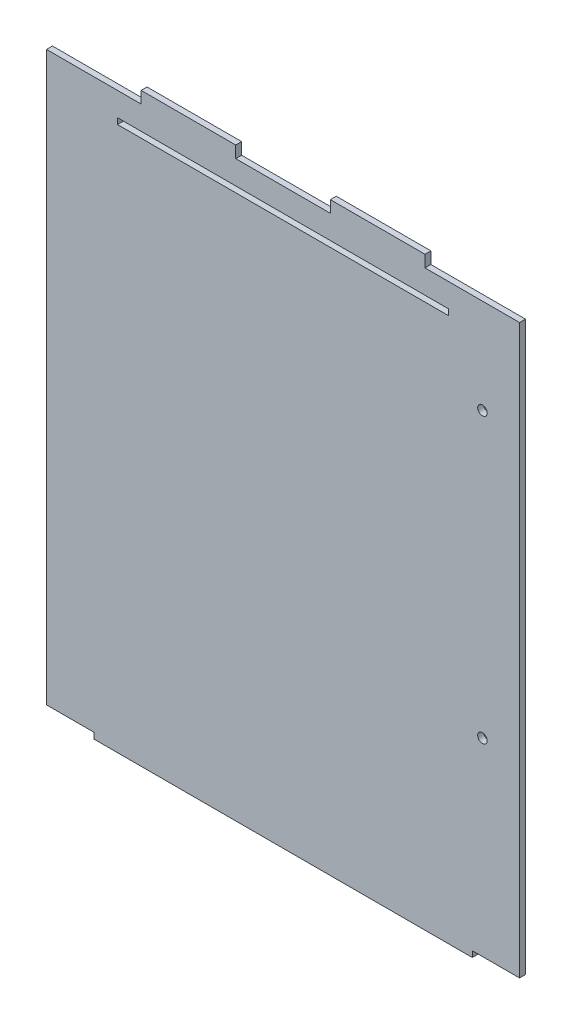
from build123d import *

# Parameters (mm, degrees)
SKETCH1_W           = 177.8
SKETCH1_H           = 3.175
BOSS_EXTRUDE1_DEPTH = 3.175
SKETCH2_R           = 2.54
CUT_EXTRUDE1_DEPTH  = 4.175


with BuildPart() as part:
    # Sketch1 → Boss-Extrude1 (new body)
    with BuildSketch(Plane.XY):
        Polygon((228.6, -6.35), (228.6, -3.175), (254, -3.175), (254, 301.625), (203.2, 301.625), (203.2, 307.975), (152.4, 307.975), (152.4, 301.625), (101.6, 301.625), (101.6, 307.975), (50.8, 307.975), (50.8, 301.625), (0, 301.625), (0, -3.175), (25.4, -3.175), (25.4, -6.35), align=None)
        with Locations((127, 287.3375)):
            Rectangle(SKETCH1_W, SKETCH1_H, mode=Mode.SUBTRACT)
    extrude(amount=BOSS_EXTRUDE1_DEPTH)

    # Sketch2 → Cut-Extrude1 (cut, through all)
    with BuildSketch(Plane(origin=(0, 0, 0), x_dir=(-1, 0, 0), z_dir=(0, 0, -1))):
        with Locations((-234.063292103, 250.825)):
            Circle(SKETCH2_R)
        with Locations((-234.063292103, 98.425)):
            Circle(SKETCH2_R)
    extrude(amount=-CUT_EXTRUDE1_DEPTH, mode=Mode.SUBTRACT)


solid = part.part
